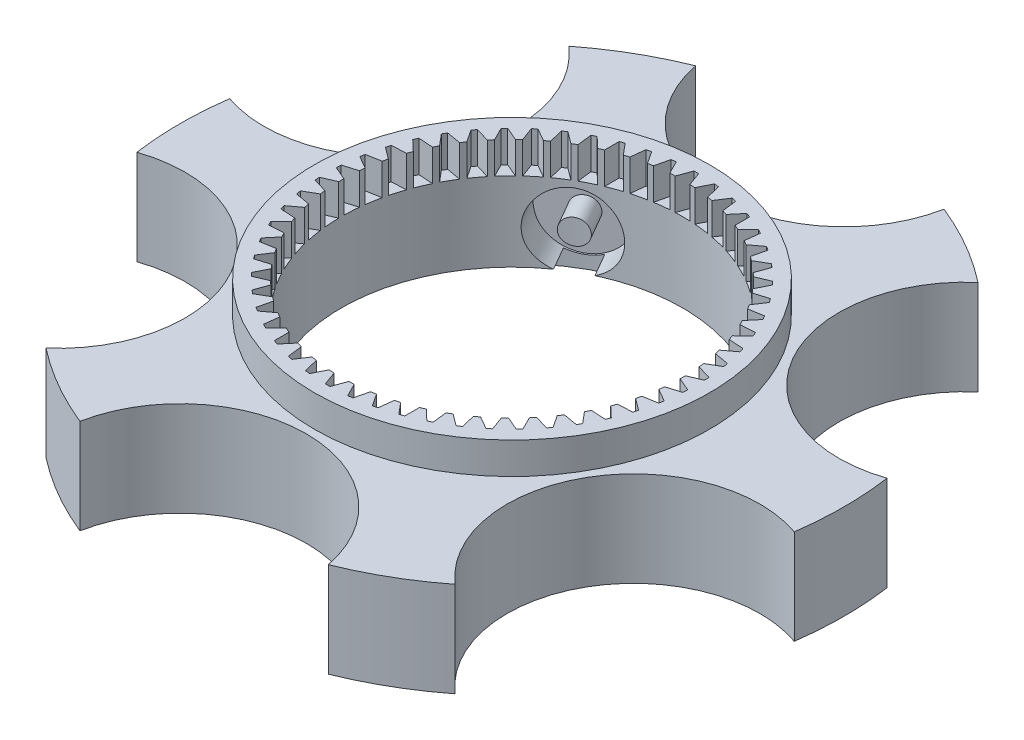
from build123d import *
from build123d.topology import SkipClean

# Parameters (mm, degrees)
BOSS_EXTRU_1_DEPTH           = 30
ESQUISSE4_R                  = 54
ENL_V_MAT_EXTRU_1_DEPTH      = 147.314899742
ESQUISSE5_R                  = 62.5
ENL_V_MAT_EXTRU_2_DEPTH      = 5
BOSS_EXTRU_2_START           = 10
ESQUISSE6_R                  = 62.5
BOSS_EXTRU_2_DEPTH           = 10
ESQUISSE8_R                  = 12
ESQUISSE8_R_2                = 3.95
ENL_V_MAT_EXTRU_3_DEPTH      = 19
R_P_TITION_CIRCULAIRE1_COUNT = 3


with BuildPart() as part:
    # Esquisse1 → Boss.-Extru.1 (new body)
    with BuildSketch(Plane(origin=(0, 0, 0), x_dir=(1, 0, 0), z_dir=(0, 1, 0))):
        with BuildLine():
            ThreePointArc((103.968214919, 14.68367415), (56.291651246, 32.5), (64.700542294, 82.697278231))
            ThreePointArc((64.700542294, 82.697278231), (52.5, 90.932667397), (39.267672625, 97.380952381))
            ThreePointArc((39.267672625, 97.380952381), (0, 65), (-39.267672625, 97.380952381))
            ThreePointArc((-39.267672625, 97.380952381), (-52.5, 90.932667397), (-64.700542294, 82.697278231))
            ThreePointArc((-64.700542294, 82.697278231), (-56.291651246, 32.5), (-103.968214919, 14.68367415))
            ThreePointArc((-103.968214919, 14.68367415), (-105, 0), (-103.968214919, -14.68367415))
            ThreePointArc((-103.968214919, -14.68367415), (-56.291651246, -32.5), (-64.700542294, -82.697278231))
            ThreePointArc((-64.700542294, -82.697278231), (-52.5, -90.932667397), (-39.267672625, -97.380952381))
            ThreePointArc((-39.267672625, -97.380952381), (0, -65), (39.267672625, -97.380952381))
            ThreePointArc((39.267672625, -97.380952381), (52.5, -90.932667397), (64.700542294, -82.697278231))
            ThreePointArc((64.700542294, -82.697278231), (56.291651246, -32.5), (103.968214919, -14.68367415))
            ThreePointArc((103.968214919, -14.68367415), (105, 0), (103.968214919, 14.68367415))
        make_face()
    extrude(amount=BOSS_EXTRU_1_DEPTH)

    # Esquisse4 → Enlèv. mat.-Extru.1 (cut, through all)
    with BuildSketch(Plane(origin=(0, 30, 0), x_dir=(1, 0, 0), z_dir=(0, 1, 0))):
        Circle(ESQUISSE4_R)
    extrude(amount=-ENL_V_MAT_EXTRU_1_DEPTH, mode=Mode.SUBTRACT)

    # Esquisse5 → Enlèv. mat.-Extru.2 (cut)
    with BuildSketch(Plane.XZ):
        Circle(ESQUISSE5_R)
    extrude(amount=-ENL_V_MAT_EXTRU_2_DEPTH, mode=Mode.SUBTRACT)

    # Esquisse6 → Boss.-Extru.2 (add)
    with SkipClean():  # the faces are left unmerged after this step: merging them gives an invalid solid
        with BuildSketch(Plane(origin=(0, 30, 0), x_dir=(1, 0, 0), z_dir=(0, 1, 0)).offset(BOSS_EXTRU_2_START)):
            Circle(ESQUISSE6_R)
            with BuildLine():
                Line((0.74, 58.295303413), (2.321534186, 53.950073948))
                ThreePointArc((2.321534186, 53.950073948), (3.139820761, 53.908640547), (3.957384499, 53.854796517))
                Line((3.957384499, 53.854796517), (6.032675268, 57.987040182))
                ThreePointArc((6.032675268, 57.987040182), (6.768216894, 57.905796256), (7.502668038, 57.815222669))
                Line((7.502668038, 57.815222669), (8.569058104, 53.31576918))
                ThreePointArc((8.569058104, 53.31576918), (9.377001594, 53.179618663), (10.182786348, 53.031225351))
                Line((10.182786348, 53.031225351), (12.723768953, 56.894601709))
                ThreePointArc((12.723768953, 56.894601709), (13.444905264, 56.728515955), (14.163875361, 56.55329022))
                Line((14.163875361, 56.55329022), (14.700700212, 51.960460095))
                ThreePointArc((14.700700212, 51.960460095), (15.487374566, 51.731433665), (16.270483481, 51.490497835))
                Line((16.270483481, 51.490497835), (19.242795489, 55.03276135))
                ThreePointArc((19.242795489, 55.03276135), (19.939774356, 54.784079792), (20.633540568, 54.526571538))
                Line((20.633540568, 54.526571538), (20.633540568, 49.902474925))
                ThreePointArc((20.633540568, 49.902474925), (21.388307366, 49.583669772), (22.138150235, 49.253449668))
                Line((22.138150235, 49.253449668), (25.501596227, 52.426697301))
                ThreePointArc((25.501596227, 52.426697301), (26.164992206, 52.098782931), (26.824172535, 51.762474514))
                Line((26.824172535, 51.762474514), (26.287347684, 47.169644388))
                ThreePointArc((26.287347684, 47.169644388), (27, 46.765371804), (27.706436486, 46.350333087))
                Line((27.706436486, 46.350333087), (31.415531624, 49.111652108))
                ThreePointArc((31.415531624, 49.111652108), (32.036373422, 48.708939405), (32.652053585, 48.29837882))
                Line((32.652053585, 48.29837882), (31.585663518, 43.79892533))
                ThreePointArc((31.585663518, 43.79892533), (32.246563952, 43.314652409), (32.900040713, 42.820407764))
                Line((32.900040713, 42.820407764), (36.904625849, 45.132456071))
                ThreePointArc((36.904625849, 45.132456071), (37.474517645, 44.660391034), (38.038371625, 44.181130408))
                Line((38.038371625, 44.181130408), (36.456837438, 39.835900944))
                ThreePointArc((36.456837438, 39.835900944), (37.057048445, 39.278176645), (37.648728329, 38.711409884))
                Line((37.648728329, 38.711409884), (41.894648318, 40.542920989))
                ThreePointArc((41.894648318, 40.542920989), (42.405883304, 40.007887488), (42.910285942, 39.466407999))
                Line((42.910285942, 39.466407999), (40.834995173, 35.334164334))
                ThreePointArc((40.834995173, 35.334164334), (41.366399928, 34.710530923), (41.88828148, 34.078906595))
                Line((41.88828148, 34.078906595), (46.318117538, 35.405112452))
                ThreePointArc((46.318117538, 35.405112452), (46.763782138, 34.814345896), (47.201912254, 34.217970126))
                Line((47.201912254, 34.217970126), (44.66092965, 30.354593768))
                ThreePointArc((44.66092965, 30.354593768), (45.116341816, 29.673484816), (45.561367482, 28.985544555))
                Line((45.561367482, 28.985544555), (50.115213677, 29.788510505))
                ThreePointArc((50.115213677, 29.788510505), (50.489281041, 29.15), (50.855213677, 28.506792908))
                Line((50.855213677, 28.506792908), (47.882901668, 24.964529393))
                ThreePointArc((47.882901668, 24.964529393), (48.256162577, 24.235155731), (48.618314149, 23.50020275))
                Line((48.618314149, 23.50020275), (53.234587522, 23.769070056))
                ThreePointArc((53.234587522, 23.769070056), (53.531999031, 23.09145036), (53.820785576, 22.410110218))
                Line((53.820785576, 22.410110218), (50.457339584, 19.236862585))
                ThreePointArc((50.457339584, 19.236862585), (50.743401522, 18.46908774), (51.017781522, 17.697061016))
                Line((51.017781522, 17.697061016), (55.634054895, 17.42819371))
                ThreePointArc((55.634054895, 17.42819371), (55.850788568, 16.720628467), (56.058523679, 16.010369232))
                Line((56.058523679, 16.010369232), (52.349428541, 13.249050211))
                ThreePointArc((52.349428541, 13.249050211), (52.544423011, 12.45325702), (52.727320919, 11.654596892))
                Line((52.727320919, 11.654596892), (57.281167114, 10.851630941))
                ThreePointArc((57.281167114, 10.851630941), (57.414292001, 10.123688758), (57.538166417, 9.394115467))
                Line((57.538166417, 9.394115467), (53.533581281, 7.082067161))
                ThreePointArc((53.533581281, 7.082067161), (53.634871318, 6.269017363), (53.723813754, 5.454524337))
                Line((53.723813754, 5.454524337), (58.153649813, 4.12831848))
                ThreePointArc((58.153649813, 4.12831848), (58.201365627, 3.389843525), (58.239704159, 2.650822406))
                Line((58.239704159, 2.650822406), (53.99378417, 0.819311302))
                ThreePointArc((53.99378417, 0.819311302), (54, 0), (53.99378417, -0.819311302))
                Line((53.99378417, -0.819311302), (58.239704159, -2.650822406))
                ThreePointArc((58.239704159, -2.650822406), (58.201365627, -3.389843525), (58.153649813, -4.12831848))
                Line((58.153649813, -4.12831848), (53.723813754, -5.454524337))
                ThreePointArc((53.723813754, -5.454524337), (53.634871318, -6.269017363), (53.533581281, -7.082067161))
                Line((53.533581281, -7.082067161), (57.538166417, -9.394115467))
                ThreePointArc((57.538166417, -9.394115467), (57.414292001, -10.123688758), (57.281167114, -10.851630941))
                Line((57.281167114, -10.851630941), (52.727320919, -11.654596892))
                ThreePointArc((52.727320919, -11.654596892), (52.544423011, -12.45325702), (52.349428541, -13.249050211))
                Line((52.349428541, -13.249050211), (56.058523679, -16.010369232))
                ThreePointArc((56.058523679, -16.010369232), (55.850788568, -16.720628467), (55.634054895, -17.42819371))
                Line((55.634054895, -17.42819371), (51.017781522, -17.697061016))
                ThreePointArc((51.017781522, -17.697061016), (50.743401522, -18.46908774), (50.457339584, -19.236862585))
                Line((50.457339584, -19.236862585), (53.820785576, -22.410110218))
                ThreePointArc((53.820785576, -22.410110218), (53.531999031, -23.09145036), (53.234587522, -23.769070056))
                Line((53.234587522, -23.769070056), (48.618314149, -23.50020275))
                ThreePointArc((48.618314149, -23.50020275), (48.256162577, -24.235155731), (47.882901668, -24.964529393))
                Line((47.882901668, -24.964529393), (50.855213677, -28.506792908))
                ThreePointArc((50.855213677, -28.506792908), (50.489281041, -29.15), (50.115213677, -29.788510505))
                Line((50.115213677, -29.788510505), (45.561367482, -28.985544555))
                ThreePointArc((45.561367482, -28.985544555), (45.116341816, -29.673484816), (44.66092965, -30.354593768))
                Line((44.66092965, -30.354593768), (47.201912254, -34.217970126))
                ThreePointArc((47.201912254, -34.217970126), (46.763782138, -34.814345896), (46.318117538, -35.405112452))
                Line((46.318117538, -35.405112452), (41.88828148, -34.078906595))
                ThreePointArc((41.88828148, -34.078906595), (41.366399928, -34.710530923), (40.834995173, -35.334164334))
                Line((40.834995173, -35.334164334), (42.910285942, -39.466407999))
                ThreePointArc((42.910285942, -39.466407999), (42.405883304, -40.007887488), (41.894648318, -40.542920989))
                Line((41.894648318, -40.542920989), (37.648728329, -38.711409884))
                ThreePointArc((37.648728329, -38.711409884), (37.057048445, -39.278176645), (36.456837438, -39.835900944))
                Line((36.456837438, -39.835900944), (38.038371625, -44.181130408))
                ThreePointArc((38.038371625, -44.181130408), (37.474517645, -44.660391034), (36.904625849, -45.132456071))
                Line((36.904625849, -45.132456071), (32.900040713, -42.820407764))
                ThreePointArc((32.900040713, -42.820407764), (32.246563952, -43.314652409), (31.585663518, -43.79892533))
                Line((31.585663518, -43.79892533), (32.652053585, -48.29837882))
                ThreePointArc((32.652053585, -48.29837882), (32.036373422, -48.708939405), (31.415531624, -49.111652108))
                Line((31.415531624, -49.111652108), (27.706436486, -46.350333087))
                ThreePointArc((27.706436486, -46.350333087), (27, -46.765371804), (26.287347684, -47.169644388))
                Line((26.287347684, -47.169644388), (26.824172535, -51.762474514))
                ThreePointArc((26.824172535, -51.762474514), (26.164992206, -52.098782931), (25.501596227, -52.426697301))
                Line((25.501596227, -52.426697301), (22.138150235, -49.253449668))
                ThreePointArc((22.138150235, -49.253449668), (21.388307366, -49.583669772), (20.633540568, -49.902474925))
                Line((20.633540568, -49.902474925), (20.633540568, -54.526571538))
                ThreePointArc((20.633540568, -54.526571538), (19.939774356, -54.784079792), (19.242795489, -55.03276135))
                Line((19.242795489, -55.03276135), (16.270483481, -51.490497835))
                ThreePointArc((16.270483481, -51.490497835), (15.487374566, -51.731433665), (14.700700212, -51.960460095))
                Line((14.700700212, -51.960460095), (14.163875361, -56.55329022))
                ThreePointArc((14.163875361, -56.55329022), (13.444905264, -56.728515955), (12.723768953, -56.894601709))
                Line((12.723768953, -56.894601709), (10.182786348, -53.031225351))
                ThreePointArc((10.182786348, -53.031225351), (9.377001594, -53.179618663), (8.569058104, -53.31576918))
                Line((8.569058104, -53.31576918), (7.502668038, -57.815222669))
                ThreePointArc((7.502668038, -57.815222669), (6.768216894, -57.905796256), (6.032675268, -57.987040182))
                Line((6.032675268, -57.987040182), (3.957384499, -53.854796517))
                ThreePointArc((3.957384499, -53.854796517), (3.139820761, -53.908640547), (2.321534186, -53.950073948))
                Line((2.321534186, -53.950073948), (0.74, -58.295303413))
                ThreePointArc((0.74, -58.295303413), (0, -58.3), (-0.74, -58.295303413))
                Line((-0.74, -58.295303413), (-2.321534186, -53.950073948))
                ThreePointArc((-2.321534186, -53.950073948), (-3.139820761, -53.908640547), (-3.957384499, -53.854796517))
                Line((-3.957384499, -53.854796517), (-6.032675268, -57.987040182))
                ThreePointArc((-6.032675268, -57.987040182), (-6.768216894, -57.905796256), (-7.502668038, -57.815222669))
                Line((-7.502668038, -57.815222669), (-8.569058104, -53.31576918))
                ThreePointArc((-8.569058104, -53.31576918), (-9.377001594, -53.179618663), (-10.182786348, -53.031225351))
                Line((-10.182786348, -53.031225351), (-12.723768953, -56.894601709))
                ThreePointArc((-12.723768953, -56.894601709), (-13.444905264, -56.728515955), (-14.163875361, -56.55329022))
                Line((-14.163875361, -56.55329022), (-14.700700212, -51.960460095))
                ThreePointArc((-14.700700212, -51.960460095), (-15.487374566, -51.731433665), (-16.270483481, -51.490497835))
                Line((-16.270483481, -51.490497835), (-19.242795489, -55.03276135))
                ThreePointArc((-19.242795489, -55.03276135), (-19.939774356, -54.784079792), (-20.633540568, -54.526571537))
                Line((-20.633540568, -54.526571537), (-20.633540568, -49.902474925))
                ThreePointArc((-20.633540568, -49.902474925), (-21.388307366, -49.583669772), (-22.138150235, -49.253449668))
                Line((-22.138150235, -49.253449668), (-25.501596227, -52.426697301))
                ThreePointArc((-25.501596227, -52.426697301), (-26.164992206, -52.098782931), (-26.824172535, -51.762474514))
                Line((-26.824172535, -51.762474514), (-26.287347684, -47.169644388))
                ThreePointArc((-26.287347684, -47.169644388), (-27, -46.765371804), (-27.706436486, -46.350333087))
                Line((-27.706436486, -46.350333087), (-31.415531624, -49.111652108))
                ThreePointArc((-31.415531624, -49.111652108), (-32.036373422, -48.708939405), (-32.652053585, -48.29837882))
                Line((-32.652053585, -48.29837882), (-31.585663518, -43.79892533))
                ThreePointArc((-31.585663518, -43.79892533), (-32.246563952, -43.314652409), (-32.900040713, -42.820407764))
                Line((-32.900040713, -42.820407764), (-36.904625849, -45.132456071))
                ThreePointArc((-36.904625849, -45.132456071), (-37.474517645, -44.660391034), (-38.038371625, -44.181130408))
                Line((-38.038371625, -44.181130408), (-36.456837438, -39.835900944))
                ThreePointArc((-36.456837438, -39.835900944), (-37.057048445, -39.278176645), (-37.648728329, -38.711409884))
                Line((-37.648728329, -38.711409884), (-41.894648318, -40.542920989))
                ThreePointArc((-41.894648318, -40.542920989), (-42.405883304, -40.007887488), (-42.910285942, -39.466407999))
                Line((-42.910285942, -39.466407999), (-40.834995173, -35.334164334))
                ThreePointArc((-40.834995173, -35.334164334), (-41.366399928, -34.710530923), (-41.88828148, -34.078906595))
                Line((-41.88828148, -34.078906595), (-46.318117538, -35.405112452))
                ThreePointArc((-46.318117538, -35.405112452), (-46.763782138, -34.814345896), (-47.201912254, -34.217970126))
                Line((-47.201912254, -34.217970126), (-44.66092965, -30.354593768))
                ThreePointArc((-44.66092965, -30.354593768), (-45.116341816, -29.673484816), (-45.561367482, -28.985544555))
                Line((-45.561367482, -28.985544555), (-50.115213677, -29.788510505))
                ThreePointArc((-50.115213677, -29.788510505), (-50.489281041, -29.15), (-50.855213677, -28.506792908))
                Line((-50.855213677, -28.506792908), (-47.882901668, -24.964529393))
                ThreePointArc((-47.882901668, -24.964529393), (-48.256162577, -24.235155731), (-48.618314149, -23.50020275))
                Line((-48.618314149, -23.50020275), (-53.234587522, -23.769070056))
                ThreePointArc((-53.234587522, -23.769070056), (-53.531999031, -23.09145036), (-53.820785576, -22.410110218))
                Line((-53.820785576, -22.410110218), (-50.457339584, -19.236862585))
                ThreePointArc((-50.457339584, -19.236862585), (-50.743401522, -18.46908774), (-51.017781522, -17.697061016))
                Line((-51.017781522, -17.697061016), (-55.634054895, -17.42819371))
                ThreePointArc((-55.634054895, -17.42819371), (-55.850788568, -16.720628467), (-56.058523679, -16.010369232))
                Line((-56.058523679, -16.010369232), (-52.349428541, -13.249050211))
                ThreePointArc((-52.349428541, -13.249050211), (-52.544423011, -12.45325702), (-52.727320919, -11.654596892))
                Line((-52.727320919, -11.654596892), (-57.281167114, -10.851630941))
                ThreePointArc((-57.281167114, -10.851630941), (-57.414292001, -10.123688758), (-57.538166417, -9.394115467))
                Line((-57.538166417, -9.394115467), (-53.533581281, -7.082067161))
                ThreePointArc((-53.533581281, -7.082067161), (-53.634871318, -6.269017363), (-53.723813754, -5.454524337))
                Line((-53.723813754, -5.454524337), (-58.153649813, -4.12831848))
                ThreePointArc((-58.153649813, -4.12831848), (-58.201365627, -3.389843525), (-58.239704159, -2.650822406))
                Line((-58.239704159, -2.650822406), (-53.99378417, -0.819311302))
                ThreePointArc((-53.99378417, -0.819311302), (-54, 0), (-53.99378417, 0.819311302))
                Line((-53.99378417, 0.819311302), (-58.239704159, 2.650822406))
                ThreePointArc((-58.239704159, 2.650822406), (-58.201365627, 3.389843525), (-58.153649813, 4.12831848))
                Line((-58.153649813, 4.12831848), (-53.723813754, 5.454524337))
                ThreePointArc((-53.723813754, 5.454524337), (-53.634871318, 6.269017363), (-53.533581281, 7.082067161))
                Line((-53.533581281, 7.082067161), (-57.538166417, 9.394115467))
                ThreePointArc((-57.538166417, 9.394115467), (-57.414292001, 10.123688758), (-57.281167114, 10.851630941))
                Line((-57.281167114, 10.851630941), (-52.727320919, 11.654596892))
                ThreePointArc((-52.727320919, 11.654596892), (-52.544423011, 12.45325702), (-52.349428541, 13.249050211))
                Line((-52.349428541, 13.249050211), (-56.058523679, 16.010369232))
                ThreePointArc((-56.058523679, 16.010369232), (-55.850788568, 16.720628467), (-55.634054895, 17.42819371))
                Line((-55.634054895, 17.42819371), (-51.017781522, 17.697061016))
                ThreePointArc((-51.017781522, 17.697061016), (-50.743401522, 18.46908774), (-50.457339584, 19.236862585))
                Line((-50.457339584, 19.236862585), (-53.820785576, 22.410110218))
                ThreePointArc((-53.820785576, 22.410110218), (-53.531999031, 23.09145036), (-53.234587522, 23.769070056))
                Line((-53.234587522, 23.769070056), (-48.618314149, 23.50020275))
                ThreePointArc((-48.618314149, 23.50020275), (-48.256162577, 24.235155731), (-47.882901668, 24.964529393))
                Line((-47.882901668, 24.964529393), (-50.855213677, 28.506792908))
                ThreePointArc((-50.855213677, 28.506792908), (-50.489281041, 29.15), (-50.115213677, 29.788510505))
                Line((-50.115213677, 29.788510505), (-45.561367482, 28.985544555))
                ThreePointArc((-45.561367482, 28.985544555), (-45.116341816, 29.673484816), (-44.66092965, 30.354593768))
                Line((-44.66092965, 30.354593768), (-47.201912254, 34.217970126))
                ThreePointArc((-47.201912254, 34.217970126), (-46.763782138, 34.814345896), (-46.318117538, 35.405112452))
                Line((-46.318117538, 35.405112452), (-41.88828148, 34.078906595))
                ThreePointArc((-41.88828148, 34.078906595), (-41.366399928, 34.710530923), (-40.834995173, 35.334164334))
                Line((-40.834995173, 35.334164334), (-42.910285942, 39.466407999))
                ThreePointArc((-42.910285942, 39.466407999), (-42.405883304, 40.007887488), (-41.894648318, 40.542920989))
                Line((-41.894648318, 40.542920989), (-37.648728329, 38.711409884))
                ThreePointArc((-37.648728329, 38.711409884), (-37.057048445, 39.278176645), (-36.456837438, 39.835900944))
                Line((-36.456837438, 39.835900944), (-38.038371625, 44.181130408))
                ThreePointArc((-38.038371625, 44.181130408), (-37.474517645, 44.660391034), (-36.904625849, 45.132456071))
                Line((-36.904625849, 45.132456071), (-32.900040713, 42.820407764))
                ThreePointArc((-32.900040713, 42.820407764), (-32.246563952, 43.314652409), (-31.585663518, 43.79892533))
                Line((-31.585663518, 43.79892533), (-32.652053585, 48.29837882))
                ThreePointArc((-32.652053585, 48.29837882), (-32.036373422, 48.708939405), (-31.415531624, 49.111652108))
                Line((-31.415531624, 49.111652108), (-27.706436486, 46.350333087))
                ThreePointArc((-27.706436486, 46.350333087), (-27, 46.765371804), (-26.287347684, 47.169644388))
                Line((-26.287347684, 47.169644388), (-26.824172535, 51.762474514))
                ThreePointArc((-26.824172535, 51.762474514), (-26.164992206, 52.098782931), (-25.501596227, 52.426697301))
                Line((-25.501596227, 52.426697301), (-22.138150235, 49.253449668))
                ThreePointArc((-22.138150235, 49.253449668), (-21.388307366, 49.583669772), (-20.633540568, 49.902474925))
                Line((-20.633540568, 49.902474925), (-20.633540568, 54.526571538))
                ThreePointArc((-20.633540568, 54.526571538), (-19.939774356, 54.784079792), (-19.242795489, 55.03276135))
                Line((-19.242795489, 55.03276135), (-16.270483481, 51.490497835))
                ThreePointArc((-16.270483481, 51.490497835), (-15.487374566, 51.731433665), (-14.700700212, 51.960460095))
                Line((-14.700700212, 51.960460095), (-14.163875361, 56.55329022))
                ThreePointArc((-14.163875361, 56.55329022), (-13.444905264, 56.728515955), (-12.723768953, 56.894601709))
                Line((-12.723768953, 56.894601709), (-10.182786348, 53.031225351))
                ThreePointArc((-10.182786348, 53.031225351), (-9.377001594, 53.179618663), (-8.569058104, 53.31576918))
                Line((-8.569058104, 53.31576918), (-7.502668038, 57.815222669))
                ThreePointArc((-7.502668038, 57.815222669), (-6.768216894, 57.905796256), (-6.032675268, 57.987040182))
                Line((-6.032675268, 57.987040182), (-3.957384499, 53.854796517))
                ThreePointArc((-3.957384499, 53.854796517), (-3.139820761, 53.908640547), (-2.321534186, 53.950073948))
                Line((-2.321534186, 53.950073948), (-0.74, 58.295303413))
                ThreePointArc((-0.74, 58.295303413), (0, 58.3), (0.74, 58.295303413))
            make_face(mode=Mode.SUBTRACT)
        extrude(amount=-BOSS_EXTRU_2_DEPTH)

    # Esquisse8 → Enlèv. mat.-Extru.3 (cut)
    with SkipClean():  # the faces are left unmerged after this step: merging them gives an invalid solid
        with BuildSketch(Plane(origin=(-22, 0, -38.105117767), x_dir=(0.8660254037844384, 0, -0.5000000000000006), z_dir=(0.5000000000000006, 0, 0.8660254037844384))):
            with Locations((0, 16)):
                Circle(ESQUISSE8_R)
            with Locations((0, 16)):
                Circle(ESQUISSE8_R_2, mode=Mode.SUBTRACT)
        enl_v_mat_extru_3 = extrude(amount=-ENL_V_MAT_EXTRU_3_DEPTH, mode=Mode.SUBTRACT)

    # Répétition circulaire1: Enlèv. mat.-Extru.3 ×3 about axis
    with SkipClean():  # the faces are left unmerged after this step: merging them gives an invalid solid
        r_p_tition_circulaire1_axis = Axis((0, 44.9965284, 0), (0, -1, 0))
        for i in range(1, R_P_TITION_CIRCULAIRE1_COUNT):
            add(enl_v_mat_extru_3.rotate(r_p_tition_circulaire1_axis, i * 360 / R_P_TITION_CIRCULAIRE1_COUNT), mode=Mode.SUBTRACT)


solid = part.part
